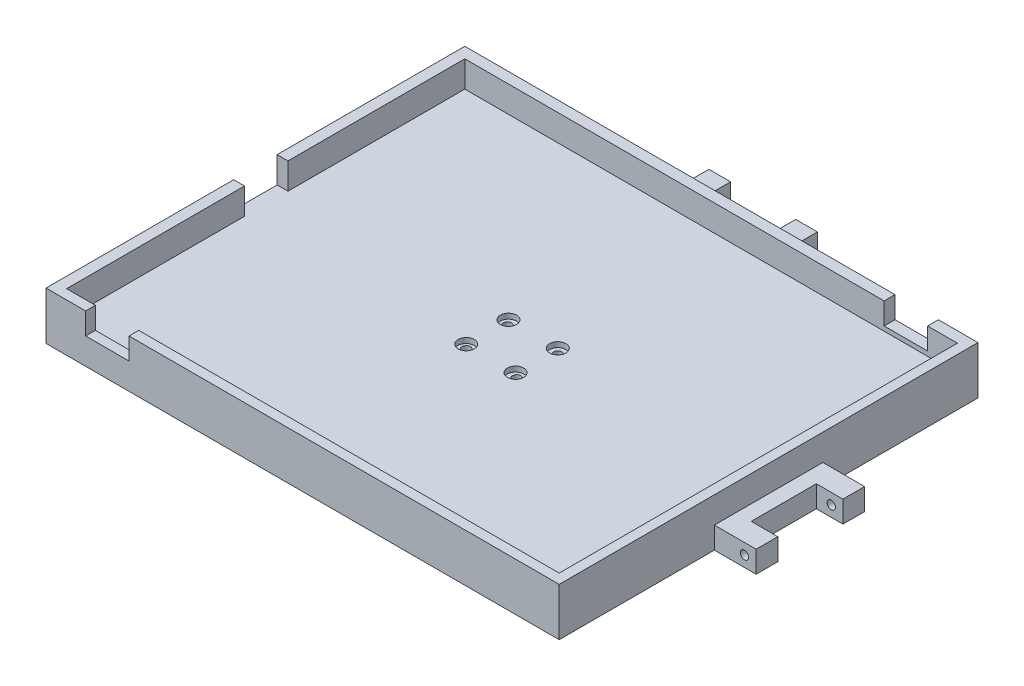
from build123d import *

# Parameters (mm, degrees)
SKETCH2_W           = 236.5
SKETCH2_H           = 193
SKETCH2_W_2         = 227
SKETCH2_H_2         = 183.5
BOSS_EXTRUDE1_DEPTH = 12.1
SKETCH3_W           = 236.5
SKETCH3_H           = 193
BOSS_EXTRUDE2_DEPTH = 10
SKETCH4_W           = 10
SKETCH4_H           = 10
CUT_EXTRUDE1_DEPTH  = 5
SKETCH7_W           = 20
SKETCH7_H           = 10
CUT_EXTRUDE2_DEPTH  = 5
SKETCH8_W           = 20
SKETCH8_H           = 10
CUT_EXTRUDE3_DEPTH  = 5
SKETCH14_W          = 25
SKETCH14_H          = 10
BOSS_EXTRUDE6_DEPTH = 19.25
SKETCH18_W          = 12.25
SKETCH18_H          = 30
CUT_EXTRUDE7_DEPTH  = 11
SKETCH19_R          = 1.925
CUT_EXTRUDE8_DEPTH  = 122.5
SKETCH21_R          = 1.925
CUT_EXTRUDE9_DEPTH  = 23.1
SKETCH22_R          = 3.75
SKETCH22_R_2        = 1.925
CUT_EXTRUDE10_DEPTH = 2.4
SKETCH27_W          = 25
SKETCH27_H          = 10
BOSS_EXTRUDE7_DEPTH = 19.25
SKETCH28_W          = 30
SKETCH28_H          = 12
CUT_EXTRUDE11_DEPTH = 19.25
SKETCH31_R          = 1.925
CUT_EXTRUDE12_DEPTH = 144.25
SKETCH32_W          = 20
SKETCH32_H          = 12.1
CUT_EXTRUDE14_DEPTH = 6


with BuildPart() as part:
    # Sketch2 → Boss-Extrude1 (new body)
    with BuildSketch(Plane(origin=(0, 0, 0), x_dir=(1, 0, 0), z_dir=(0, 1, 0))):
        with Locations((113.25, -91.5)):
            Rectangle(SKETCH2_W, SKETCH2_H)
        with Locations((113.5, -91.75)):
            Rectangle(SKETCH2_W_2, SKETCH2_H_2, mode=Mode.SUBTRACT)
    extrude(amount=BOSS_EXTRUDE1_DEPTH)

    # Sketch3 → Boss-Extrude2 (add)
    with BuildSketch(Plane.XZ):
        with Locations((113.25, 91.5)):
            Rectangle(SKETCH3_W, SKETCH3_H)
    extrude(amount=BOSS_EXTRUDE2_DEPTH)

    # Sketch4 → Cut-Extrude1 (cut)
    with BuildSketch(Plane.ZY.offset(5)):
        with Locations((96.5, 7.1)):
            Rectangle(SKETCH4_W, SKETCH4_H)
        with Locations((86.5, 7.1)):
            Rectangle(SKETCH4_W, SKETCH4_H)
    extrude(amount=-CUT_EXTRUDE1_DEPTH, mode=Mode.SUBTRACT)

    # Sketch7 → Cut-Extrude2 (cut)
    with BuildSketch(Plane.XY.offset(188)):
        with Locations((23.25, 7.1)):
            Rectangle(SKETCH7_W, SKETCH7_H)
    extrude(amount=-CUT_EXTRUDE2_DEPTH, mode=Mode.SUBTRACT)

    # Sketch8 → Cut-Extrude3 (cut)
    with BuildSketch(Plane(origin=(0, 0, -5), x_dir=(-1, 0, 0), z_dir=(0, 0, -1))):
        with Locations((-203.25, 7.1)):
            Rectangle(SKETCH8_W, SKETCH8_H)
    extrude(amount=-CUT_EXTRUDE3_DEPTH, mode=Mode.SUBTRACT)

    # Sketch14 → Boss-Extrude6 (add)
    with BuildSketch(Plane(origin=(231.5, 0, 0), x_dir=(0, 0, -1), z_dir=(1, 0, 0))):
        with Locations((-104, -5)):
            Rectangle(SKETCH14_W, SKETCH14_H)
        with Locations((-79, -5)):
            Rectangle(SKETCH14_W, SKETCH14_H)
    extrude(amount=BOSS_EXTRUDE6_DEPTH)

    # Sketch18 → Cut-Extrude7 (cut, through all)
    with BuildSketch(Plane(origin=(0, 0, 0), x_dir=(1, 0, 0), z_dir=(0, 1, 0))):
        with Locations((244.625, -91.5)):
            Rectangle(SKETCH18_W, SKETCH18_H)
    extrude(amount=-CUT_EXTRUDE7_DEPTH, mode=Mode.SUBTRACT)

    # Sketch19 → Cut-Extrude8 (cut, through all)
    with BuildSketch(Plane.XY.offset(116.5)):
        with Locations((245.378954084, -5)):
            Circle(SKETCH19_R)
    extrude(amount=-CUT_EXTRUDE8_DEPTH, mode=Mode.SUBTRACT)

    # Sketch21 → Cut-Extrude9 (cut, through all)
    with BuildSketch(Plane.XZ.offset(10)):
        with Locations((124.871391666, 82.016158176)):
            Circle(SKETCH21_R)
        with Locations((124.871391666, 100.983841824)):
            Circle(SKETCH21_R)
        with Locations((101.628608334, 100.983841824)):
            Circle(SKETCH21_R)
        with Locations((101.628608334, 82.016158176)):
            Circle(SKETCH21_R)
    extrude(amount=-CUT_EXTRUDE9_DEPTH, mode=Mode.SUBTRACT)

    # Sketch22 → Cut-Extrude10 (cut)
    with BuildSketch(Plane(origin=(0, 0, 0), x_dir=(1, 0, 0), z_dir=(0, 1, 0))):
        with Locations((102.128608334, -82.016158176)):
            Circle(SKETCH22_R)
        with Locations((101.628608334, -82.016158176)):
            Circle(SKETCH22_R_2, mode=Mode.SUBTRACT)
        with Locations((124.871391666, -82.016158176)):
            Circle(SKETCH22_R)
        with Locations((124.871391666, -82.016158176)):
            Circle(SKETCH22_R_2, mode=Mode.SUBTRACT)
        with Locations((124.871391666, -101.483841824)):
            Circle(SKETCH22_R)
        with Locations((124.871391666, -100.983841824)):
            Circle(SKETCH22_R_2, mode=Mode.SUBTRACT)
        with Locations((102.128608334, -101.483841824)):
            Circle(SKETCH22_R)
        with Locations((101.628608334, -100.983841824)):
            Circle(SKETCH22_R_2, mode=Mode.SUBTRACT)
    extrude(amount=-CUT_EXTRUDE10_DEPTH, mode=Mode.SUBTRACT)

    # Sketch27 → Boss-Extrude7 (add)
    with BuildSketch(Plane(origin=(0, 0, -5), x_dir=(-1, 0, 0), z_dir=(0, 0, -1))):
        with Locations((-125.75, -5)):
            Rectangle(SKETCH27_W, SKETCH27_H)
        with Locations((-100.75, -5)):
            Rectangle(SKETCH27_W, SKETCH27_H)
    extrude(amount=BOSS_EXTRUDE7_DEPTH)

    # Sketch28 → Cut-Extrude11 (cut)
    with BuildSketch(Plane(origin=(0, 0, 0), x_dir=(1, 0, 0), z_dir=(0, 1, 0))):
        with Locations((113.25, 18.25)):
            Rectangle(SKETCH28_W, SKETCH28_H)
    extrude(amount=-CUT_EXTRUDE11_DEPTH, mode=Mode.SUBTRACT)

    # Sketch31 → Cut-Extrude12 (cut, through all)
    with BuildSketch(Plane(origin=(138.25, 0, 0), x_dir=(0, 0, -1), z_dir=(1, 0, 0))):
        with Locations((18.88, -5)):
            Circle(SKETCH31_R)
    extrude(amount=-CUT_EXTRUDE12_DEPTH, mode=Mode.SUBTRACT)

    # Sketch32 → Cut-Extrude14 (cut, through all)
    with BuildSketch(Plane(origin=(0, 0, 0), x_dir=(0, 0, -1), z_dir=(1, 0, 0))):
        with Locations((-91.5, 6.05)):
            Rectangle(SKETCH32_W, SKETCH32_H)
    extrude(amount=-CUT_EXTRUDE14_DEPTH, mode=Mode.SUBTRACT)


solid = part.part
